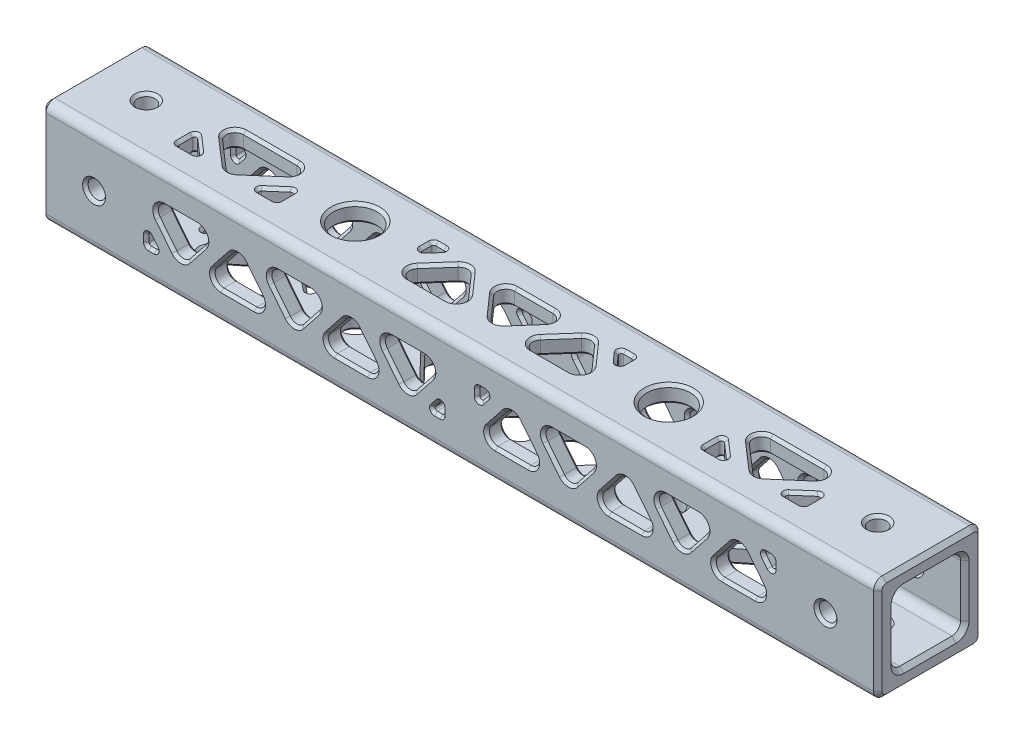
from build123d import *

# Parameters (mm, degrees)
SKETCH1_W                          = 19.05
SKETCH1_H                          = 19.05
SKETCH1_W_2                        = 12.7
SKETCH1_H_2                        = 12.7
BOSS_EXTRUDE1_DEPTH                = 76.2
F_1_8_0_125_DIAMETER_HOLE1_D       = 3.175
F_1_8_0_125_DIAMETER_HOLE2_D       = 3.175
F_3_16_0_1875_DIAMETER_HOLE1_D     = 4.7625
F_3_16_0_1875_DIAMETER_HOLE1_DEPTH = 3.175
CUT_EXTRUDE3_REACH                 = 21.05
SKETCH10_R                         = 3.96875
CUT_EXTRUDE2_REACH                 = 21.05
CUT_EXTRUDE4_REACH                 = 21.05
CUT_EXTRUDE5_DEPTH                 = 3.175
CIRPATTERN2_COUNT                  = 4
FILLET1_R                          = 1.5875
FILLET2_R                          = 0.396875
CHAMFER2_SIZE                      = 0.762
CHAMFER3_SIZE                      = 0.508


with BuildPart() as part:
    # Sketch1 → Boss-Extrude1 (new body, symmetric)
    with BuildSketch(Plane(origin=(0, 0, 0), x_dir=(0, 0, -1), z_dir=(1, 0, 0))):
        Rectangle(SKETCH1_W, SKETCH1_H)
        Rectangle(SKETCH1_W_2, SKETCH1_H_2, mode=Mode.SUBTRACT)
    extrude(amount=BOSS_EXTRUDE1_DEPTH, both=True)

    # 1/8 (0.125) Diameter Hole1 (through all)
    with Locations(Plane.XY.offset(9.525)):
        with Locations((-66.675, 0), (66.675, 0)):
            Hole(F_1_8_0_125_DIAMETER_HOLE1_D / 2)

    # 1/8 (0.125) Diameter Hole2 (through all)
    with Locations(Plane(origin=(0, 9.525, 0), x_dir=(1, 0, 0), z_dir=(0, 1, 0))):
        with Locations((-66.675, 0), (66.675, 0)):
            Hole(F_1_8_0_125_DIAMETER_HOLE2_D / 2)

    # 3/16 (0.1875) Diameter Hole1
    with Locations(Plane(origin=(0, -9.525, 0), x_dir=(-1, 0, 0), z_dir=(0, -1, 0))):
        with Locations((28.575, 0), (-28.575, 0)):
            Hole(F_3_16_0_1875_DIAMETER_HOLE1_D / 2, depth=F_3_16_0_1875_DIAMETER_HOLE1_DEPTH)

    # Sketch10 → Cut-Extrude3 (cut, up to next)
    with BuildSketch(Plane(origin=(0, 9.525, 0), x_dir=(1, 0, 0), z_dir=(0, 1, 0)), mode=Mode.PRIVATE) as cut_extrude3_sk1:
        with Locations((-28.575, 0)):
            Circle(SKETCH10_R)
    cut_extrude3_tool1 = extrude(cut_extrude3_sk1.sketch, amount=-CUT_EXTRUDE3_REACH, mode=Mode.PRIVATE) & part.part
    add(cut_extrude3_tool1.solids().sort_by_distance((-28.575, 9.525, 0))[0], mode=Mode.SUBTRACT)
    # Sketch10 → Cut-Extrude3 (cut, up to next)
    with BuildSketch(Plane(origin=(0, 9.525, 0), x_dir=(1, 0, 0), z_dir=(0, 1, 0)), mode=Mode.PRIVATE) as cut_extrude3_sk2:
        with Locations((28.575, 0)):
            Circle(SKETCH10_R)
    cut_extrude3_tool2 = extrude(cut_extrude3_sk2.sketch, amount=-CUT_EXTRUDE3_REACH, mode=Mode.PRIVATE) & part.part
    add(cut_extrude3_tool2.solids().sort_by_distance((28.575, 9.525, 0))[0], mode=Mode.SUBTRACT)

    # Sketch9 → Cut-Extrude2 (cut, up to next)
    with BuildSketch(Plane.XZ.offset(9.525), mode=Mode.PRIVATE) as cut_extrude2_sk1:
        Polygon((-19.84375, 3.96875), (-19.84375, 0.588438592), (-16.560790165, 3.96875), align=None)
    cut_extrude2_tool1 = extrude(cut_extrude2_sk1.sketch, amount=-CUT_EXTRUDE2_REACH, mode=Mode.PRIVATE) & part.part
    add(cut_extrude2_tool1.solids().sort_by_distance((-18.74943, -9.525, 2.84198))[0], mode=Mode.SUBTRACT)
    # Sketch9 → Cut-Extrude2 (cut, up to next)
    with BuildSketch(Plane.XZ.offset(9.525), mode=Mode.PRIVATE) as cut_extrude2_sk2:
        Polygon((-19.84375, -3.96875), (-12.134846722, 3.96875), (-4.425943443, -3.96875), align=None)
    cut_extrude2_tool2 = extrude(cut_extrude2_sk2.sketch, amount=-CUT_EXTRUDE2_REACH, mode=Mode.PRIVATE) & part.part
    add(cut_extrude2_tool2.solids().sort_by_distance((-12.134847, -9.525, -1.322917))[0], mode=Mode.SUBTRACT)
    # Sketch9 → Cut-Extrude2 (cut, up to next)
    with BuildSketch(Plane.XZ.offset(9.525), mode=Mode.PRIVATE) as cut_extrude2_sk3:
        Polygon((-7.708903278, 3.96875), (0, -3.96875), (7.708903278, 3.96875), align=None)
    cut_extrude2_tool3 = extrude(cut_extrude2_sk3.sketch, amount=-CUT_EXTRUDE2_REACH, mode=Mode.PRIVATE) & part.part
    add(cut_extrude2_tool3.solids().sort_by_distance((0, -9.525, 1.322917))[0], mode=Mode.SUBTRACT)
    # Sketch9 → Cut-Extrude2 (cut, up to next)
    with BuildSketch(Plane.XZ.offset(9.525), mode=Mode.PRIVATE) as cut_extrude2_sk4:
        Polygon((19.84375, -3.96875), (12.134846722, 3.96875), (4.425943443, -3.96875), align=None)
    cut_extrude2_tool4 = extrude(cut_extrude2_sk4.sketch, amount=-CUT_EXTRUDE2_REACH, mode=Mode.PRIVATE) & part.part
    add(cut_extrude2_tool4.solids().sort_by_distance((12.134847, -9.525, -1.322917))[0], mode=Mode.SUBTRACT)
    # Sketch9 → Cut-Extrude2 (cut, up to next)
    with BuildSketch(Plane.XZ.offset(9.525), mode=Mode.PRIVATE) as cut_extrude2_sk5:
        Polygon((16.560790165, 3.96875), (19.84375, 3.96875), (19.84375, 0.588438592), align=None)
    cut_extrude2_tool5 = extrude(cut_extrude2_sk5.sketch, amount=-CUT_EXTRUDE2_REACH, mode=Mode.PRIVATE) & part.part
    add(cut_extrude2_tool5.solids().sort_by_distance((18.74943, -9.525, 2.84198))[0], mode=Mode.SUBTRACT)
    # Sketch9 → Cut-Extrude2 (cut, up to next)
    with BuildSketch(Plane.XZ.offset(9.525), mode=Mode.PRIVATE) as cut_extrude2_sk6:
        Polygon((-37.30625, -3.96875), (-37.30625, -0.097233891), (-42.145645137, -3.96875), align=None)
    cut_extrude2_tool6 = extrude(cut_extrude2_sk6.sketch, amount=-CUT_EXTRUDE2_REACH, mode=Mode.PRIVATE) & part.part
    add(cut_extrude2_tool6.solids().sort_by_distance((-38.919382, -9.525, -2.678245))[0], mode=Mode.SUBTRACT)
    # Sketch9 → Cut-Extrude2 (cut, up to next)
    with BuildSketch(Plane.XZ.offset(9.525), mode=Mode.PRIVATE) as cut_extrude2_sk7:
        Polygon((-57.15, -3.96875), (-57.15, -0.097233891), (-52.310604863, -3.96875), align=None)
    cut_extrude2_tool7 = extrude(cut_extrude2_sk7.sketch, amount=-CUT_EXTRUDE2_REACH, mode=Mode.PRIVATE) & part.part
    add(cut_extrude2_tool7.solids().sort_by_distance((-55.536868, -9.525, -2.678245))[0], mode=Mode.SUBTRACT)
    # Sketch9 → Cut-Extrude2 (cut, up to next)
    with BuildSketch(Plane.XZ.offset(9.525), mode=Mode.PRIVATE) as cut_extrude2_sk8:
        Polygon((-57.15, 3.96875), (-47.228125, -3.96875), (-37.30625, 3.96875), align=None)
    cut_extrude2_tool8 = extrude(cut_extrude2_sk8.sketch, amount=-CUT_EXTRUDE2_REACH, mode=Mode.PRIVATE) & part.part
    add(cut_extrude2_tool8.solids().sort_by_distance((-47.228125, -9.525, 1.322917))[0], mode=Mode.SUBTRACT)
    # Sketch9 → Cut-Extrude2 (cut, up to next)
    with BuildSketch(Plane.XZ.offset(9.525), mode=Mode.PRIVATE) as cut_extrude2_sk9:
        Polygon((37.30625, -0.097233891), (37.30625, -3.96875), (42.145645137, -3.96875), align=None)
    cut_extrude2_tool9 = extrude(cut_extrude2_sk9.sketch, amount=-CUT_EXTRUDE2_REACH, mode=Mode.PRIVATE) & part.part
    add(cut_extrude2_tool9.solids().sort_by_distance((38.919382, -9.525, -2.678245))[0], mode=Mode.SUBTRACT)
    # Sketch9 → Cut-Extrude2 (cut, up to next)
    with BuildSketch(Plane.XZ.offset(9.525), mode=Mode.PRIVATE) as cut_extrude2_sk10:
        Polygon((52.310604863, -3.96875), (57.15, -3.96875), (57.15, -0.097233891), align=None)
    cut_extrude2_tool10 = extrude(cut_extrude2_sk10.sketch, amount=-CUT_EXTRUDE2_REACH, mode=Mode.PRIVATE) & part.part
    add(cut_extrude2_tool10.solids().sort_by_distance((55.536868, -9.525, -2.678245))[0], mode=Mode.SUBTRACT)
    # Sketch9 → Cut-Extrude2 (cut, up to next)
    with BuildSketch(Plane.XZ.offset(9.525), mode=Mode.PRIVATE) as cut_extrude2_sk11:
        Polygon((37.30625, 3.96875), (47.228125, -3.96875), (57.15, 3.96875), align=None)
    cut_extrude2_tool11 = extrude(cut_extrude2_sk11.sketch, amount=-CUT_EXTRUDE2_REACH, mode=Mode.PRIVATE) & part.part
    add(cut_extrude2_tool11.solids().sort_by_distance((47.228125, -9.525, 1.322917))[0], mode=Mode.SUBTRACT)

    # Sketch11 → Cut-Extrude4 (cut, up to next)
    with BuildSketch(Plane(origin=(0, 9.525, 0), x_dir=(1, 0, 0), z_dir=(0, 1, 0)), mode=Mode.PRIVATE) as cut_extrude4_sk1:
        Polygon((-57.15, -3.96875), (-57.15, -0.238746376), (-52.860495833, -3.96875), align=None)
    cut_extrude4_tool1 = extrude(cut_extrude4_sk1.sketch, amount=-CUT_EXTRUDE4_REACH, mode=Mode.PRIVATE) & part.part
    add(cut_extrude4_tool1.solids().sort_by_distance((-55.720165, 9.525, 2.725415))[0], mode=Mode.SUBTRACT)
    # Sketch11 → Cut-Extrude4 (cut, up to next)
    with BuildSketch(Plane(origin=(0, 9.525, 0), x_dir=(1, 0, 0), z_dir=(0, 1, 0)), mode=Mode.PRIVATE) as cut_extrude4_sk2:
        Polygon((-57.15, 3.96875), (-48.021875, -3.96875), (-38.89375, 3.96875), align=None)
    cut_extrude4_tool2 = extrude(cut_extrude4_sk2.sketch, amount=-CUT_EXTRUDE4_REACH, mode=Mode.PRIVATE) & part.part
    add(cut_extrude4_tool2.solids().sort_by_distance((-48.021875, 9.525, -1.322917))[0], mode=Mode.SUBTRACT)
    # Sketch11 → Cut-Extrude4 (cut, up to next)
    with BuildSketch(Plane(origin=(0, 9.525, 0), x_dir=(1, 0, 0), z_dir=(0, 1, 0)), mode=Mode.PRIVATE) as cut_extrude4_sk3:
        Polygon((-43.183254167, -3.96875), (-38.89375, -3.96875), (-38.89375, -0.238746376), align=None)
    cut_extrude4_tool3 = extrude(cut_extrude4_sk3.sketch, amount=-CUT_EXTRUDE4_REACH, mode=Mode.PRIVATE) & part.part
    add(cut_extrude4_tool3.solids().sort_by_distance((-40.323585, 9.525, 2.725415))[0], mode=Mode.SUBTRACT)
    # Sketch11 → Cut-Extrude4 (cut, up to next)
    with BuildSketch(Plane(origin=(0, 9.525, 0), x_dir=(1, 0, 0), z_dir=(0, 1, 0)), mode=Mode.PRIVATE) as cut_extrude4_sk4:
        Polygon((-18.25625, 3.96875), (-18.25625, 0.827576232), (-15.48206643, 3.96875), align=None)
    cut_extrude4_tool4 = extrude(cut_extrude4_sk4.sketch, amount=-CUT_EXTRUDE4_REACH, mode=Mode.PRIVATE) & part.part
    add(cut_extrude4_tool4.solids().sort_by_distance((-17.331522, 9.525, -2.921692))[0], mode=Mode.SUBTRACT)
    # Sketch11 → Cut-Extrude4 (cut, up to next)
    with BuildSketch(Plane(origin=(0, 9.525, 0), x_dir=(1, 0, 0), z_dir=(0, 1, 0)), mode=Mode.PRIVATE) as cut_extrude4_sk5:
        Polygon((15.48206643, 3.96875), (18.25625, 3.96875), (18.25625, 0.827576232), align=None)
    cut_extrude4_tool5 = extrude(cut_extrude4_sk5.sketch, amount=-CUT_EXTRUDE4_REACH, mode=Mode.PRIVATE) & part.part
    add(cut_extrude4_tool5.solids().sort_by_distance((17.331522, 9.525, -2.921692))[0], mode=Mode.SUBTRACT)
    # Sketch11 → Cut-Extrude4 (cut, up to next)
    with BuildSketch(Plane(origin=(0, 9.525, 0), x_dir=(1, 0, 0), z_dir=(0, 1, 0)), mode=Mode.PRIVATE) as cut_extrude4_sk6:
        Polygon((-18.25625, -3.96875), (-11.246105477, 3.96875), (-4.235960953, -3.96875), align=None)
    cut_extrude4_tool6 = extrude(cut_extrude4_sk6.sketch, amount=-CUT_EXTRUDE4_REACH, mode=Mode.PRIVATE) & part.part
    add(cut_extrude4_tool6.solids().sort_by_distance((-11.246105, 9.525, 1.322917))[0], mode=Mode.SUBTRACT)
    # Sketch11 → Cut-Extrude4 (cut, up to next)
    with BuildSketch(Plane(origin=(0, 9.525, 0), x_dir=(1, 0, 0), z_dir=(0, 1, 0)), mode=Mode.PRIVATE) as cut_extrude4_sk7:
        Polygon((-7.010144523, 3.96875), (0, -3.96875), (7.010144523, 3.96875), align=None)
    cut_extrude4_tool7 = extrude(cut_extrude4_sk7.sketch, amount=-CUT_EXTRUDE4_REACH, mode=Mode.PRIVATE) & part.part
    add(cut_extrude4_tool7.solids().sort_by_distance((0, 9.525, -1.322917))[0], mode=Mode.SUBTRACT)
    # Sketch11 → Cut-Extrude4 (cut, up to next)
    with BuildSketch(Plane(origin=(0, 9.525, 0), x_dir=(1, 0, 0), z_dir=(0, 1, 0)), mode=Mode.PRIVATE) as cut_extrude4_sk8:
        Polygon((18.25625, -3.96875), (11.246105477, 3.96875), (4.235960953, -3.96875), align=None)
    cut_extrude4_tool8 = extrude(cut_extrude4_sk8.sketch, amount=-CUT_EXTRUDE4_REACH, mode=Mode.PRIVATE) & part.part
    add(cut_extrude4_tool8.solids().sort_by_distance((11.246105, 9.525, 1.322917))[0], mode=Mode.SUBTRACT)
    # Sketch11 → Cut-Extrude4 (cut, up to next)
    with BuildSketch(Plane(origin=(0, 9.525, 0), x_dir=(1, 0, 0), z_dir=(0, 1, 0)), mode=Mode.PRIVATE) as cut_extrude4_sk9:
        Polygon((38.89375, -0.238746376), (38.89375, -3.96875), (43.183254167, -3.96875), align=None)
    cut_extrude4_tool9 = extrude(cut_extrude4_sk9.sketch, amount=-CUT_EXTRUDE4_REACH, mode=Mode.PRIVATE) & part.part
    add(cut_extrude4_tool9.solids().sort_by_distance((40.323585, 9.525, 2.725415))[0], mode=Mode.SUBTRACT)
    # Sketch11 → Cut-Extrude4 (cut, up to next)
    with BuildSketch(Plane(origin=(0, 9.525, 0), x_dir=(1, 0, 0), z_dir=(0, 1, 0)), mode=Mode.PRIVATE) as cut_extrude4_sk10:
        Polygon((52.860495833, -3.96875), (57.15, -3.96875), (57.15, -0.238746376), align=None)
    cut_extrude4_tool10 = extrude(cut_extrude4_sk10.sketch, amount=-CUT_EXTRUDE4_REACH, mode=Mode.PRIVATE) & part.part
    add(cut_extrude4_tool10.solids().sort_by_distance((55.720165, 9.525, 2.725415))[0], mode=Mode.SUBTRACT)
    # Sketch11 → Cut-Extrude4 (cut, up to next)
    with BuildSketch(Plane(origin=(0, 9.525, 0), x_dir=(1, 0, 0), z_dir=(0, 1, 0)), mode=Mode.PRIVATE) as cut_extrude4_sk11:
        Polygon((38.89375, 3.96875), (48.021875, -3.96875), (57.15, 3.96875), align=None)
    cut_extrude4_tool11 = extrude(cut_extrude4_sk11.sketch, amount=-CUT_EXTRUDE4_REACH, mode=Mode.PRIVATE) & part.part
    add(cut_extrude4_tool11.solids().sort_by_distance((48.021875, 9.525, -1.322917))[0], mode=Mode.SUBTRACT)

    # Sketch13 → Cut-Extrude5 (cut)
    with BuildSketch(Plane.XY.offset(9.525)):
        Polygon((-57.15, -1.141145373), (-57.15, -3.96875), (-54.907718384, -3.96875), align=None)
        Polygon((-3.175, -3.96875), (-3.175, -1.141145373), (-5.417281616, -3.96875), align=None)
        Polygon((-30.1625, -3.96875), (-36.456912646, 3.96875), (-23.868087354, 3.96875), align=None)
        Polygon((-57.15, 3.96875), (-50.855587354, -3.96875), (-44.561174708, 3.96875), align=None)
        Polygon((-3.175, 3.96875), (-9.469412646, -3.96875), (-15.763825292, 3.96875), align=None)
        Polygon((-46.803456323, -3.96875), (-40.509043677, 3.96875), (-34.214631031, -3.96875), align=None)
        Polygon((-26.110368969, -3.96875), (-19.815956323, 3.96875), (-13.521543677, -3.96875), align=None)
        Polygon((3.175, 3.96875), (3.175, 1.141145373), (5.417281616, 3.96875), align=None)
        Polygon((57.15, 3.96875), (57.15, 1.141145373), (54.907718384, 3.96875), align=None)
        Polygon((23.868087354, -3.96875), (30.1625, 3.96875), (36.456912646, -3.96875), align=None)
        Polygon((3.175, -3.96875), (9.469412646, 3.96875), (15.763825292, -3.96875), align=None)
        Polygon((13.521543677, 3.96875), (19.815956323, -3.96875), (26.110368969, 3.96875), align=None)
        Polygon((57.15, -3.96875), (50.855587354, 3.96875), (44.561174708, -3.96875), align=None)
        Polygon((34.214631031, 3.96875), (40.509043677, -3.96875), (46.803456323, 3.96875), align=None)
    cut_extrude5 = extrude(amount=-CUT_EXTRUDE5_DEPTH, mode=Mode.SUBTRACT)

    # CirPattern2: Cut-Extrude5 ×4 about axis, 2 skipped
    cirpattern2_axis = Axis((-82.07375, 0, 0), (1, 0, 0))
    add([cut_extrude5.rotate(cirpattern2_axis, i * 360 / CIRPATTERN2_COUNT) for i in range(1, CIRPATTERN2_COUNT) if i not in (1, 3)], mode=Mode.SUBTRACT)

    # Fillet1
    fillet1_edges = [part.edges().sort_by_distance(p)[0] for p in [
        (47.228125, -7.9375, -3.96875),
        (57.15, -7.9375, 3.96875),
        (37.30625, -7.9375, 3.96875),
        (12.134846722, -7.9375, 3.96875),
        (4.425943443, -7.9375, -3.96875),
        (19.84375, -7.9375, -3.96875),
        (-12.134846722, -7.9375, 3.96875),
        (-19.84375, -7.9375, -3.96875),
        (-4.425943443, -7.9375, -3.96875),
        (0, -6.35, -6.35),
        (0, 6.35, -6.35),
        (0, -7.9375, -3.96875),
        (7.708903278, -7.9375, 3.96875),
        (-7.708903278, -7.9375, 3.96875),
        (0, 6.35, 6.35),
        (-47.228125, -7.9375, -3.96875),
        (-37.30625, -7.9375, 3.96875),
        (-57.15, -7.9375, 3.96875),
        (0, -6.35, 6.35),
        (-4.235960953, 7.9375, 3.96875),
        (-18.25625, 7.9375, 3.96875),
        (-11.246105477, 7.9375, -3.96875),
        (18.25625, 7.9375, 3.96875),
        (4.235960953, 7.9375, 3.96875),
        (11.246105477, 7.9375, -3.96875),
        (38.89375, 7.9375, -3.96875),
        (57.15, 7.9375, -3.96875),
        (48.021875, 7.9375, 3.96875),
        (-7.010144523, 7.9375, -3.96875),
        (0, 7.9375, 3.96875),
        (7.010144523, 7.9375, -3.96875),
        (-57.15, 7.9375, -3.96875),
        (-38.89375, 7.9375, -3.96875),
        (-48.021875, 7.9375, 3.96875),
        (50.855587354, 3.96875, 7.9375),
        (44.561174708, -3.96875, 7.9375),
        (57.15, -3.96875, 7.9375),
        (-36.456912646, 3.96875, 7.9375),
        (-30.1625, -3.96875, 7.9375),
        (-23.868087354, 3.96875, 7.9375),
        (-9.469412646, -3.96875, 7.9375),
        (-3.175, 3.96875, 7.9375),
        (-15.763825292, 3.96875, 7.9375),
        (9.469412646, 3.96875, 7.9375),
        (3.175, -3.96875, 7.9375),
        (15.763825292, -3.96875, 7.9375),
        (40.509043677, -3.96875, 7.9375),
        (46.803456323, 3.96875, 7.9375),
        (34.214631031, 3.96875, 7.9375),
        (30.1625, 3.96875, 7.9375),
        (23.868087354, -3.96875, 7.9375),
        (36.456912646, -3.96875, 7.9375),
        (19.815956323, -3.96875, 7.9375),
        (26.110368969, 3.96875, 7.9375),
        (13.521543677, 3.96875, 7.9375),
        (-19.815956323, 3.96875, 7.9375),
        (-26.110368969, -3.96875, 7.9375),
        (-13.521543677, -3.96875, 7.9375),
        (-40.509043677, 3.96875, 7.9375),
        (-46.803456323, -3.96875, 7.9375),
        (-34.214631031, -3.96875, 7.9375),
        (-50.855587354, -3.96875, 7.9375),
        (-44.561174708, 3.96875, 7.9375),
        (-57.15, 3.96875, 7.9375),
        (57.15, 3.96875, -7.9375),
        (44.561174708, 3.96875, -7.9375),
        (50.855587354, -3.96875, -7.9375),
        (-36.456912646, -3.96875, -7.9375),
        (-30.1625, 3.96875, -7.9375),
        (-23.868087354, -3.96875, -7.9375),
        (-15.763825292, -3.96875, -7.9375),
        (-3.175, -3.96875, -7.9375),
        (-9.469412646, 3.96875, -7.9375),
        (15.763825292, 3.96875, -7.9375),
        (3.175, 3.96875, -7.9375),
        (9.469412646, -3.96875, -7.9375),
        (34.214631031, -3.96875, -7.9375),
        (46.803456323, -3.96875, -7.9375),
        (40.509043677, 3.96875, -7.9375),
        (36.456912646, 3.96875, -7.9375),
        (23.868087354, 3.96875, -7.9375),
        (30.1625, -3.96875, -7.9375),
        (13.521543677, -3.96875, -7.9375),
        (26.110368969, -3.96875, -7.9375),
        (19.815956323, 3.96875, -7.9375),
        (-13.521543677, 3.96875, -7.9375),
        (-26.110368969, 3.96875, -7.9375),
        (-19.815956323, -3.96875, -7.9375),
        (-34.214631031, 3.96875, -7.9375),
        (-46.803456323, 3.96875, -7.9375),
        (-40.509043677, -3.96875, -7.9375),
        (-57.15, -3.96875, -7.9375),
        (-44.561174708, -3.96875, -7.9375),
        (-50.855587354, 3.96875, -7.9375),
        (0, -9.525, -9.525),
        (0, -9.525, 9.525),
        (0, 9.525, 9.525),
        (0, 9.525, -9.525),
    ]]
    fillet(fillet1_edges, radius=FILLET1_R)

    # Fillet2
    fillet2_edges = [part.edges().sort_by_distance(p)[0] for p in [
        (37.30625, -7.9375, -0.097233891),
        (37.30625, -7.9375, -3.96875),
        (42.145645137, -7.9375, -3.96875),
        (16.560790165, -7.9375, 3.96875),
        (19.84375, -7.9375, 0.588438592),
        (19.84375, -7.9375, 3.96875),
        (-19.84375, -7.9375, 0.588438592),
        (-16.560790165, -7.9375, 3.96875),
        (-19.84375, -7.9375, 3.96875),
        (-37.30625, -7.9375, -0.097233891),
        (-42.145645137, -7.9375, -3.96875),
        (-37.30625, -7.9375, -3.96875),
        (-57.15, -7.9375, -0.097233891),
        (-57.15, -7.9375, -3.96875),
        (-52.310604863, -7.9375, -3.96875),
        (52.310604863, -7.9375, -3.96875),
        (57.15, -7.9375, -3.96875),
        (57.15, -7.9375, -0.097233891),
        (-38.89375, 7.9375, 3.96875),
        (-38.89375, 7.9375, 0.238746376),
        (-43.183254167, 7.9375, 3.96875),
        (43.183254167, 7.9375, 3.96875),
        (38.89375, 7.9375, 3.96875),
        (38.89375, 7.9375, 0.238746376),
        (57.15, 7.9375, 0.238746376),
        (57.15, 7.9375, 3.96875),
        (52.860495833, 7.9375, 3.96875),
        (15.48206643, 7.9375, -3.96875),
        (18.25625, 7.9375, -0.827576232),
        (18.25625, 7.9375, -3.96875),
        (-18.25625, 7.9375, -3.96875),
        (-15.48206643, 7.9375, -3.96875),
        (-18.25625, 7.9375, -0.827576232),
        (-52.860495833, 7.9375, 3.96875),
        (-57.15, 7.9375, 3.96875),
        (-57.15, 7.9375, 0.238746376),
        (3.175, 1.141145373, 7.9375),
        (5.417281616, 3.96875, 7.9375),
        (3.175, 3.96875, 7.9375),
        (57.15, 1.141145373, 7.9375),
        (57.15, 3.96875, 7.9375),
        (54.907718384, 3.96875, 7.9375),
        (-57.15, -1.141145373, 7.9375),
        (-57.15, -3.96875, 7.9375),
        (-54.907718384, -3.96875, 7.9375),
        (-3.175, -1.141145373, 7.9375),
        (-5.417281616, -3.96875, 7.9375),
        (-3.175, -3.96875, 7.9375),
        (3.175, -3.96875, -7.9375),
        (3.175, -1.141145373, -7.9375),
        (5.417281616, -3.96875, -7.9375),
        (54.907718384, -3.96875, -7.9375),
        (57.15, -3.96875, -7.9375),
        (57.15, -1.141145373, -7.9375),
        (-54.907718384, 3.96875, -7.9375),
        (-57.15, 3.96875, -7.9375),
        (-57.15, 1.141145373, -7.9375),
        (-3.175, 3.96875, -7.9375),
        (-3.175, 1.141145373, -7.9375),
        (-5.417281616, 3.96875, -7.9375),
    ]]
    fillet(fillet2_edges, radius=FILLET2_R)

    # Chamfer2
    chamfer2_edges = [part.edges().sort_by_distance(p)[0] for p in [
        (-76.2, 0, -6.35),
        (76.2, 0, -6.35),
        (-76.2, 6.35, 0),
        (76.2, 6.35, 0),
        (-76.2, -6.35, 0),
        (76.2, -6.35, 0),
        (-76.2, 0, 6.35),
        (76.2, 0, 6.35),
        (-76.2, 0, -9.525),
        (76.2, 0, -9.525),
        (-76.2, -9.525, 0),
        (-76.2, 0, 9.525),
        (-76.2, 9.525, 0),
        (-76.2, 9.060032015, 9.060032015),
        (-76.2, 9.060032015, -9.060032015),
        (-76.2, -9.060032015, 9.060032015),
        (-76.2, -9.060032015, -9.060032015),
        (76.2, -9.525, 0),
        (76.2, 9.525, 0),
        (76.2, 0, 9.525),
        (76.2, 9.060032015, 9.060032015),
        (76.2, 9.060032015, -9.060032015),
        (76.2, -9.060032015, 9.060032015),
        (76.2, -9.060032015, -9.060032015),
        (-76.2, 5.885032015, -5.885032015),
        (76.2, 5.885032015, -5.885032015),
        (-76.2, -5.885032015, -5.885032015),
        (76.2, -5.885032015, -5.885032015),
        (-76.2, -5.885032015, 5.885032015),
        (76.2, -5.885032015, 5.885032015),
        (-76.2, 5.885032015, 5.885032015),
        (76.2, 5.885032015, 5.885032015),
    ]]
    chamfer(chamfer2_edges, length=CHAMFER2_SIZE)

    # Chamfer3
    chamfer3_edges = [part.edges().sort_by_distance(p)[0] for p in [
        (56.241040198, -3.96875, -9.525),
        (56.241040198, -3.96875, -6.35),
        (57.15, -2.926116079, -9.525),
        (57.15, -2.926116079, -6.35),
        (55.930073421, -2.679520399, -9.525),
        (55.930073421, -2.679520399, -6.35),
        (4.083959802, -3.96875, -9.525),
        (4.083959802, -3.96875, -6.35),
        (4.394926579, -2.679520399, -9.525),
        (4.394926579, -2.679520399, -6.35),
        (3.175, -2.926116079, -9.525),
        (3.175, -2.926116079, -6.35),
        (-4.083959802, 3.96875, -9.525),
        (-4.083959802, 3.96875, -6.35),
        (-4.394926579, 2.679520399, -9.525),
        (-4.394926579, 2.679520399, -6.35),
        (-3.175, 2.926116079, -9.525),
        (-3.175, 2.926116079, -6.35),
        (-56.241040198, 3.96875, -9.525),
        (-56.241040198, 3.96875, -6.35),
        (-57.15, 2.926116079, -9.525),
        (-57.15, 2.926116079, -6.35),
        (-55.930073421, 2.679520399, -9.525),
        (-55.930073421, 2.679520399, -6.35),
        (17.110721888, 9.525, -3.96875),
        (17.110721888, 6.35, -3.96875),
        (18.25625, 9.525, -2.724184334),
        (18.25625, 6.35, -2.724184334),
        (16.813250278, 9.525, -2.461466982),
        (16.813250278, 6.35, -2.461466982),
        (-17.110721888, 9.525, -3.96875),
        (-17.110721888, 6.35, -3.96875),
        (-16.813250278, 9.525, -2.461466982),
        (-16.813250278, 6.35, -2.461466982),
        (-18.25625, 9.525, -2.724184334),
        (-18.25625, 6.35, -2.724184334),
        (3.175, 2.926116079, 9.525),
        (3.175, 2.926116079, 6.35),
        (4.083959802, 3.96875, 9.525),
        (4.083959802, 3.96875, 6.35),
        (4.394926579, 2.679520399, 9.525),
        (4.394926579, 2.679520399, 6.35),
        (55.930073421, 2.679520399, 9.525),
        (55.930073421, 2.679520399, 6.35),
        (56.241040198, 3.96875, 9.525),
        (56.241040198, 3.96875, 6.35),
        (57.15, 2.926116079, 9.525),
        (57.15, 2.926116079, 6.35),
        (-3.175, -2.926116079, 9.525),
        (-3.175, -2.926116079, 6.35),
        (-4.083959802, -3.96875, 9.525),
        (-4.083959802, -3.96875, 6.35),
        (-4.394926579, -2.679520399, 9.525),
        (-4.394926579, -2.679520399, 6.35),
        (-55.930073421, -2.679520399, 9.525),
        (-55.930073421, -2.679520399, 6.35),
        (-56.241040198, -3.96875, 9.525),
        (-56.241040198, -3.96875, 6.35),
        (-57.15, -2.926116079, 9.525),
        (-57.15, -2.926116079, 6.35),
        (55.337427343, 9.525, 3.96875),
        (55.337427343, 6.35, 3.96875),
        (55.077006416, 9.525, 2.041349493),
        (55.077006416, 6.35, 2.041349493),
        (57.15, 9.525, 2.340833559),
        (57.15, 6.35, 2.340833559),
        (38.89375, 9.525, 2.340833559),
        (38.89375, 6.35, 2.340833559),
        (40.966743584, 9.525, 2.041349493),
        (40.966743584, 6.35, 2.041349493),
        (40.706322657, 9.525, 3.96875),
        (40.706322657, 6.35, 3.96875),
        (-40.706322657, 9.525, 3.96875),
        (-40.706322657, 6.35, 3.96875),
        (-40.966743584, 9.525, 2.041349493),
        (-40.966743584, 6.35, 2.041349493),
        (-38.89375, 9.525, 2.340833559),
        (-38.89375, 6.35, 2.340833559),
        (-57.15, 9.525, 2.340833559),
        (-57.15, 6.35, 2.340833559),
        (-55.077006416, 9.525, 2.041349493),
        (-55.077006416, 6.35, 2.041349493),
        (-55.337427343, 9.525, 3.96875),
        (-55.337427343, 6.35, 3.96875),
        (54.849640951, -9.525, -1.93752113),
        (54.849640951, -6.35, -1.93752113),
        (57.15, -9.525, -2.247428439),
        (57.15, -6.35, -2.247428439),
        (55.097566798, -9.525, -3.96875),
        (55.097566798, -6.35, -3.96875),
        (39.606609049, -9.525, -1.93752113),
        (39.606609049, -6.35, -1.93752113),
        (39.358683202, -9.525, -3.96875),
        (39.358683202, -6.35, -3.96875),
        (37.30625, -9.525, -2.247428439),
        (37.30625, -6.35, -2.247428439),
        (18.473176629, -9.525, 3.96875),
        (18.473176629, -6.35, 3.96875),
        (19.84375, -9.525, 2.569302969),
        (19.84375, -6.35, 2.569302969),
        (18.188473912, -9.525, 2.292799572),
        (18.188473912, -6.35, 2.292799572),
        (-19.84375, -9.525, 2.569302969),
        (-19.84375, -6.35, 2.569302969),
        (-18.473176629, -9.525, 3.96875),
        (-18.473176629, -6.35, 3.96875),
        (-18.188473912, -9.525, 2.292799572),
        (-18.188473912, -6.35, 2.292799572),
        (-39.358683202, -9.525, -3.96875),
        (-39.358683202, -6.35, -3.96875),
        (-39.606609049, -9.525, -1.93752113),
        (-39.606609049, -6.35, -1.93752113),
        (-37.30625, -9.525, -2.247428439),
        (-37.30625, -6.35, -2.247428439),
        (-54.849640951, -9.525, -1.93752113),
        (-54.849640951, -6.35, -1.93752113),
        (-55.097566798, -9.525, -3.96875),
        (-55.097566798, -6.35, -3.96875),
        (-57.15, -9.525, -2.247428439),
        (-57.15, -6.35, -2.247428439),
        (57.033758004, -3.852508004, -9.525),
        (57.033758004, -3.852508004, -6.35),
        (55.371619821, -3.744562731, -9.525),
        (55.371619821, -3.744562731, -6.35),
        (56.883690742, -1.905574084, -9.525),
        (56.883690742, -1.905574084, -6.35),
        (4.953380179, -3.744562731, -9.525),
        (4.953380179, -3.744562731, -6.35),
        (3.291241996, -3.852508004, -9.525),
        (3.291241996, -3.852508004, -6.35),
        (3.441309258, -1.905574084, -9.525),
        (3.441309258, -1.905574084, -6.35),
        (-4.953380179, 3.744562731, -9.525),
        (-4.953380179, 3.744562731, -6.35),
        (-3.441309258, 1.905574084, -9.525),
        (-3.441309258, 1.905574084, -6.35),
        (-3.291241996, 3.852508004, -9.525),
        (-3.291241996, 3.852508004, -6.35),
        (-57.033758004, 3.852508004, -9.525),
        (-57.033758004, 3.852508004, -6.35),
        (-56.883690742, 1.905574084, -9.525),
        (-56.883690742, 1.905574084, -6.35),
        (-55.371619821, 3.744562731, -9.525),
        (-55.371619821, 3.744562731, -6.35),
        (18.140008004, 9.525, -3.852508004),
        (18.140008004, 6.35, -3.852508004),
        (17.999822001, 9.525, -1.50530045),
        (17.999822001, 6.35, -1.50530045),
        (16.000284506, 9.525, -3.735037215),
        (16.000284506, 6.35, -3.735037215),
        (-16.000284506, 9.525, -3.735037215),
        (-16.000284506, 6.35, -3.735037215),
        (-17.999822001, 9.525, -1.50530045),
        (-17.999822001, 6.35, -1.50530045),
        (-18.140008004, 9.525, -3.852508004),
        (-18.140008004, 6.35, -3.852508004),
        (3.291241996, 3.852508004, 9.525),
        (3.291241996, 3.852508004, 6.35),
        (3.441309258, 1.905574084, 9.525),
        (3.441309258, 1.905574084, 6.35),
        (4.953380179, 3.744562731, 9.525),
        (4.953380179, 3.744562731, 6.35),
        (55.371619821, 3.744562731, 9.525),
        (55.371619821, 3.744562731, 6.35),
        (56.883690742, 1.905574084, 9.525),
        (56.883690742, 1.905574084, 6.35),
        (57.033758004, 3.852508004, 9.525),
        (57.033758004, 3.852508004, 6.35),
        (-3.291241996, -3.852508004, 9.525),
        (-3.291241996, -3.852508004, 6.35),
        (-3.441309258, -1.905574084, 9.525),
        (-3.441309258, -1.905574084, 6.35),
        (-4.953380179, -3.744562731, 9.525),
        (-4.953380179, -3.744562731, 6.35),
        (-55.371619821, -3.744562731, 9.525),
        (-55.371619821, -3.744562731, 6.35),
        (-56.883690742, -1.905574084, 9.525),
        (-56.883690742, -1.905574084, 6.35),
        (-57.033758004, -3.852508004, 9.525),
        (-57.033758004, -3.852508004, 6.35),
        (53.549998934, 9.525, 3.710893032),
        (53.549998934, 6.35, 3.710893032),
        (56.917677742, 9.525, 0.74863819),
        (56.917677742, 6.35, 0.74863819),
        (57.033758004, 9.525, 3.852508004),
        (57.033758004, 6.35, 3.852508004),
        (39.126072258, 9.525, 0.74863819),
        (39.126072258, 6.35, 0.74863819),
        (42.493751066, 9.525, 3.710893032),
        (42.493751066, 6.35, 3.710893032),
        (39.009991996, 9.525, 3.852508004),
        (39.009991996, 6.35, 3.852508004),
        (-42.493751066, 9.525, 3.710893032),
        (-42.493751066, 6.35, 3.710893032),
        (-39.126072258, 9.525, 0.74863819),
        (-39.126072258, 6.35, 0.74863819),
        (-39.009991996, 9.525, 3.852508004),
        (-39.009991996, 6.35, 3.852508004),
        (-56.917677742, 9.525, 0.74863819),
        (-56.917677742, 6.35, 0.74863819),
        (-53.549998934, 9.525, 3.710893032),
        (-53.549998934, 6.35, 3.710893032),
        (-57.033758004, 9.525, 3.852508004),
        (-57.033758004, 6.35, 3.852508004),
        (56.925046777, -9.525, -0.565277155),
        (56.925046777, -6.35, -0.565277155),
        (53.067506107, -9.525, -3.70324338),
        (53.067506107, -6.35, -3.70324338),
        (57.033758004, -9.525, -3.852508004),
        (57.033758004, -6.35, -3.852508004),
        (41.388743893, -9.525, -3.70324338),
        (41.388743893, -6.35, -3.70324338),
        (37.531203223, -9.525, -0.565277155),
        (37.531203223, -6.35, -0.565277155),
        (37.422491996, -9.525, -3.852508004),
        (37.422491996, -6.35, -3.852508004),
        (19.727508004, -9.525, 3.852508004),
        (19.727508004, -6.35, 3.852508004),
        (17.133932741, -9.525, 3.726426739),
        (17.133932741, -6.35, 3.726426739),
        (19.596070132, -9.525, 1.198966641),
        (19.596070132, -6.35, 1.198966641),
        (-19.727508004, -9.525, 3.852508004),
        (-19.727508004, -6.35, 3.852508004),
        (-17.133932741, -9.525, 3.726426739),
        (-17.133932741, -6.35, 3.726426739),
        (-19.596070132, -9.525, 1.198966641),
        (-19.596070132, -6.35, 1.198966641),
        (-41.388743893, -9.525, -3.70324338),
        (-41.388743893, -6.35, -3.70324338),
        (-37.531203223, -9.525, -0.565277155),
        (-37.531203223, -6.35, -0.565277155),
        (-37.422491996, -9.525, -3.852508004),
        (-37.422491996, -6.35, -3.852508004),
        (-53.067506107, -9.525, -3.70324338),
        (-53.067506107, -6.35, -3.70324338),
        (-56.925046777, -9.525, -0.565277155),
        (-56.925046777, -6.35, -0.565277155),
        (-57.033758004, -9.525, -3.852508004),
        (-57.033758004, -6.35, -3.852508004),
        (68.2625, 0, 6.35),
        (68.2625, 0, -6.35),
        (68.2625, 0, -9.525),
        (68.2625, 0, 9.525),
        (-65.0875, 0, 6.35),
        (-65.0875, 0, -6.35),
        (-65.0875, 0, -9.525),
        (-65.0875, 0, 9.525),
        (68.2625, -6.35, 0),
        (68.2625, 6.35, 0),
        (68.2625, 9.525, 0),
        (68.2625, -9.525, 0),
        (-65.0875, -6.35, 0),
        (-65.0875, 6.35, 0),
        (-65.0875, 9.525, 0),
        (-65.0875, -9.525, 0),
        (48.106987947, -0.502658877, -9.525),
        (48.106987947, -0.502658877, -6.35),
        (53.604186761, -0.502658877, -9.525),
        (53.604186761, -0.502658877, -6.35),
        (50.855587354, 3.96875, -9.525),
        (50.855587354, 3.96875, -6.35),
        (40.509043677, -3.96875, -9.525),
        (40.509043677, -3.96875, -6.35),
        (43.257643084, 0.502658877, -9.525),
        (43.257643084, 0.502658877, -6.35),
        (37.76044427, 0.502658877, -9.525),
        (37.76044427, 0.502658877, -6.35),
        (27.413900593, -0.502658877, -9.525),
        (27.413900593, -0.502658877, -6.35),
        (32.911099407, -0.502658877, -9.525),
        (32.911099407, -0.502658877, -6.35),
        (30.1625, 3.96875, -9.525),
        (30.1625, 3.96875, -6.35),
        (19.815956323, -3.96875, -9.525),
        (19.815956323, -3.96875, -6.35),
        (22.56455573, 0.502658877, -9.525),
        (22.56455573, 0.502658877, -6.35),
        (17.067356916, 0.502658877, -9.525),
        (17.067356916, 0.502658877, -6.35),
        (6.720813239, -0.502658877, -9.525),
        (6.720813239, -0.502658877, -6.35),
        (12.218012053, -0.502658877, -9.525),
        (12.218012053, -0.502658877, -6.35),
        (9.469412646, 3.96875, -9.525),
        (9.469412646, 3.96875, -6.35),
        (-9.469412646, -3.96875, -9.525),
        (-9.469412646, -3.96875, -6.35),
        (-6.720813239, 0.502658877, -9.525),
        (-6.720813239, 0.502658877, -6.35),
        (-12.218012053, 0.502658877, -9.525),
        (-12.218012053, 0.502658877, -6.35),
        (26.19375, -9.525, 0),
        (26.19375, -6.35, 0),
        (-22.56455573, -0.502658877, -9.525),
        (-22.56455573, -0.502658877, -6.35),
        (-17.067356916, -0.502658877, -9.525),
        (-17.067356916, -0.502658877, -6.35),
        (-19.815956323, 3.96875, -9.525),
        (-19.815956323, 3.96875, -6.35),
        (-30.1625, -3.96875, -9.525),
        (-30.1625, -3.96875, -6.35),
        (-27.413900593, 0.502658877, -9.525),
        (-27.413900593, 0.502658877, -6.35),
        (-32.911099407, 0.502658877, -9.525),
        (-32.911099407, 0.502658877, -6.35),
        (-43.257643084, -0.502658877, -9.525),
        (-43.257643084, -0.502658877, -6.35),
        (-37.76044427, -0.502658877, -9.525),
        (-37.76044427, -0.502658877, -6.35),
        (-40.509043677, 3.96875, -9.525),
        (-40.509043677, 3.96875, -6.35),
        (-50.855587354, -3.96875, -9.525),
        (-50.855587354, -3.96875, -6.35),
        (-48.106987947, 0.502658877, -9.525),
        (-48.106987947, 0.502658877, -6.35),
        (-53.604186761, 0.502658877, -9.525),
        (-53.604186761, 0.502658877, -6.35),
        (47.228125, -9.525, 3.96875),
        (47.228125, -6.35, 3.96875),
        (50.917958422, -9.525, -1.016883262),
        (50.917958422, -6.35, -1.016883262),
        (43.538291578, -9.525, -1.016883262),
        (43.538291578, -6.35, -1.016883262),
        (15.250733041, -9.525, 0.760466439),
        (15.250733041, -6.35, 0.760466439),
        (12.134846722, -9.525, -3.96875),
        (12.134846722, -6.35, -3.96875),
        (9.018960402, -9.525, 0.760466439),
        (9.018960402, -6.35, 0.760466439),
        (-3.11588632, -9.525, -0.760466439),
        (-3.11588632, -6.35, -0.760466439),
        (0, -9.525, 3.96875),
        (0, -6.35, 3.96875),
        (3.11588632, -9.525, -0.760466439),
        (3.11588632, -6.35, -0.760466439),
        (-9.018960402, -9.525, 0.760466439),
        (-9.018960402, -6.35, 0.760466439),
        (-12.134846722, -9.525, -3.96875),
        (-12.134846722, -6.35, -3.96875),
        (-30.95625, -9.525, 0),
        (-15.250733041, -9.525, 0.760466439),
        (-15.250733041, -6.35, 0.760466439),
        (-30.95625, -6.35, 0),
        (-50.917958422, -9.525, -1.016883262),
        (-50.917958422, -6.35, -1.016883262),
        (-47.228125, -9.525, 3.96875),
        (-47.228125, -6.35, 3.96875),
        (-43.538291578, -9.525, -1.016883262),
        (-43.538291578, -6.35, -1.016883262),
        (53.604186761, 0.502658877, 9.525),
        (53.604186761, 0.502658877, 6.35),
        (50.855587354, -3.96875, 9.525),
        (50.855587354, -3.96875, 6.35),
        (48.106987947, 0.502658877, 9.525),
        (48.106987947, 0.502658877, 6.35),
        (37.76044427, -0.502658877, 9.525),
        (37.76044427, -0.502658877, 6.35),
        (40.509043677, 3.96875, 9.525),
        (40.509043677, 3.96875, 6.35),
        (43.257643084, -0.502658877, 9.525),
        (43.257643084, -0.502658877, 6.35),
        (32.911099407, 0.502658877, 9.525),
        (32.911099407, 0.502658877, 6.35),
        (30.1625, -3.96875, 9.525),
        (30.1625, -3.96875, 6.35),
        (27.413900593, 0.502658877, 9.525),
        (27.413900593, 0.502658877, 6.35),
        (17.067356916, -0.502658877, 9.525),
        (17.067356916, -0.502658877, 6.35),
        (19.815956323, 3.96875, 9.525),
        (19.815956323, 3.96875, 6.35),
        (22.56455573, -0.502658877, 9.525),
        (22.56455573, -0.502658877, 6.35),
        (12.218012053, 0.502658877, 9.525),
        (12.218012053, 0.502658877, 6.35),
        (9.469412646, -3.96875, 9.525),
        (9.469412646, -3.96875, 6.35),
        (6.720813239, 0.502658877, 9.525),
        (6.720813239, 0.502658877, 6.35),
        (-12.218012053, -0.502658877, 9.525),
        (-12.218012053, -0.502658877, 6.35),
        (-9.469412646, 3.96875, 9.525),
        (-9.469412646, 3.96875, 6.35),
        (-6.720813239, -0.502658877, 9.525),
        (-6.720813239, -0.502658877, 6.35),
        (-17.067356916, 0.502658877, 9.525),
        (-17.067356916, 0.502658877, 6.35),
        (-19.815956323, -3.96875, 9.525),
        (-19.815956323, -3.96875, 6.35),
        (-22.56455573, 0.502658877, 9.525),
        (-22.56455573, 0.502658877, 6.35),
        (-30.1625, 3.96875, 9.525),
        (-30.1625, 3.96875, 6.35),
        (-27.413900593, -0.502658877, 9.525),
        (-27.413900593, -0.502658877, 6.35),
        (-32.911099407, -0.502658877, 9.525),
        (-32.911099407, -0.502658877, 6.35),
        (-37.76044427, 0.502658877, 9.525),
        (-37.76044427, 0.502658877, 6.35),
        (-40.509043677, -3.96875, 9.525),
        (-40.509043677, -3.96875, 6.35),
        (-43.257643084, 0.502658877, 9.525),
        (-43.257643084, 0.502658877, 6.35),
        (-32.54375, 6.35, 0),
        (-53.604186761, -0.502658877, 9.525),
        (-53.604186761, -0.502658877, 6.35),
        (-32.54375, 9.525, 0),
        (-50.855587354, 3.96875, 9.525),
        (-50.855587354, 3.96875, 6.35),
        (-48.106987947, -0.502658877, 9.525),
        (-48.106987947, -0.502658877, 6.35),
        (48.021875, 9.525, -3.96875),
        (48.021875, 6.35, -3.96875),
        (51.505153502, 9.525, 0.939812172),
        (51.505153502, 6.35, 0.939812172),
        (44.538596498, 9.525, 0.939812172),
        (44.538596498, 6.35, 0.939812172),
        (8.311151465, 9.525, -0.645537848),
        (8.311151465, 6.35, -0.645537848),
        (14.181059488, 9.525, -0.645537848),
        (24.60625, 6.35, 0),
        (14.181059488, 6.35, -0.645537848),
        (24.60625, 9.525, 0),
        (11.246105477, 9.525, 3.96875),
        (11.246105477, 6.35, 3.96875),
        (0, 9.525, -3.96875),
        (0, 6.35, -3.96875),
        (2.934954011, 9.525, 0.645537848),
        (2.934954011, 6.35, 0.645537848),
        (-2.934954011, 9.525, 0.645537848),
        (-2.934954011, 6.35, 0.645537848),
        (-11.246105477, 9.525, 3.96875),
        (-11.246105477, 6.35, 3.96875),
        (-14.181059488, 9.525, -0.645537848),
        (-14.181059488, 6.35, -0.645537848),
        (-8.311151465, 9.525, -0.645537848),
        (-8.311151465, 6.35, -0.645537848),
        (-48.021875, 9.525, -3.96875),
        (-48.021875, 6.35, -3.96875),
        (-44.538596498, 9.525, 0.939812172),
        (-44.538596498, 6.35, 0.939812172),
        (-51.505153502, 9.525, 0.939812172),
        (-51.505153502, 6.35, 0.939812172),
        (50.855587354, -3.001302314, -9.525),
        (50.855587354, -3.001302314, -6.35),
        (55.294394255, 3.072000925, -9.525),
        (55.294394255, 3.072000925, -6.35),
        (46.416780453, 3.072000925, -9.525),
        (46.416780453, 3.072000925, -6.35),
        (44.947850578, -3.072000925, -9.525),
        (44.947850578, -3.072000925, -6.35),
        (36.070236776, -3.072000925, -9.525),
        (36.070236776, -3.072000925, -6.35),
        (40.509043677, 3.001302314, -9.525),
        (40.509043677, 3.001302314, -6.35),
        (30.1625, -3.001302314, -9.525),
        (30.1625, -3.001302314, -6.35),
        (34.601306901, 3.072000925, -9.525),
        (34.601306901, 3.072000925, -6.35),
        (25.723693099, 3.072000925, -9.525),
        (25.723693099, 3.072000925, -6.35),
        (24.254763224, -3.072000925, -9.525),
        (24.254763224, -3.072000925, -6.35),
        (15.377149422, -3.072000925, -9.525),
        (15.377149422, -3.072000925, -6.35),
        (19.815956323, 3.001302314, -9.525),
        (19.815956323, 3.001302314, -6.35),
        (9.469412646, -3.001302314, -9.525),
        (9.469412646, -3.001302314, -6.35),
        (13.908219547, 3.072000925, -9.525),
        (13.908219547, 3.072000925, -6.35),
        (5.030605745, 3.072000925, -9.525),
        (5.030605745, 3.072000925, -6.35),
        (-5.030605745, -3.072000925, -9.525),
        (-5.030605745, -3.072000925, -6.35),
        (-13.908219547, -3.072000925, -9.525),
        (-13.908219547, -3.072000925, -6.35),
        (-9.469412646, 3.001302314, -9.525),
        (-9.469412646, 3.001302314, -6.35),
        (-19.815956323, -3.001302314, -9.525),
        (-19.815956323, -3.001302314, -6.35),
        (-15.377149422, 3.072000925, -9.525),
        (-15.377149422, 3.072000925, -6.35),
        (-24.254763224, 3.072000925, -9.525),
        (-24.254763224, 3.072000925, -6.35),
        (-25.723693099, -3.072000925, -9.525),
        (-25.723693099, -3.072000925, -6.35),
        (-34.601306901, -3.072000925, -9.525),
        (-34.601306901, -3.072000925, -6.35),
        (-30.1625, 3.001302314, -9.525),
        (-30.1625, 3.001302314, -6.35),
        (-40.509043677, -3.001302314, -9.525),
        (-40.509043677, -3.001302314, -6.35),
        (-36.070236776, 3.072000925, -9.525),
        (-36.070236776, 3.072000925, -6.35),
        (-44.947850578, 3.072000925, -9.525),
        (-44.947850578, 3.072000925, -6.35),
        (-46.416780453, -3.072000925, -9.525),
        (-46.416780453, -3.072000925, -6.35),
        (-55.294394255, -3.072000925, -9.525),
        (-55.294394255, -3.072000925, -6.35),
        (-50.855587354, 3.001302314, -9.525),
        (-50.855587354, 3.001302314, -6.35),
        (54.122395025, -9.525, 2.90672352),
        (54.122395025, -6.35, 2.90672352),
        (47.228125, -9.525, -3.523258055),
        (47.228125, -6.35, -3.523258055),
        (40.333854975, -9.525, 2.90672352),
        (40.333854975, -6.35, 2.90672352),
        (17.551179694, -9.525, -2.999456956),
        (17.551179694, -6.35, -2.999456956),
        (6.718513749, -9.525, -2.999456956),
        (6.718513749, -6.35, -2.999456956),
        (12.134846722, -9.525, 3.277655704),
        (12.134846722, -6.35, 3.277655704),
        (-5.416332972, -9.525, 2.999456956),
        (-5.416332972, -6.35, 2.999456956),
        (5.416332972, -9.525, 2.999456956),
        (5.416332972, -6.35, 2.999456956),
        (0, -9.525, -3.277655704),
        (0, -6.35, -3.277655704),
        (-6.718513749, -9.525, -2.999456956),
        (-6.718513749, -6.35, -2.999456956),
        (-17.551179694, -9.525, -2.999456956),
        (-17.551179694, -6.35, -2.999456956),
        (-12.134846722, -9.525, 3.277655704),
        (-12.134846722, -6.35, 3.277655704),
        (-54.122395025, -9.525, 2.90672352),
        (-54.122395025, -6.35, 2.90672352),
        (-47.228125, -9.525, -3.523258055),
        (-47.228125, -6.35, -3.523258055),
        (-40.333854975, -9.525, 2.90672352),
        (-40.333854975, -6.35, 2.90672352),
        (55.294394255, -3.072000925, 9.525),
        (55.294394255, -3.072000925, 6.35),
        (50.855587354, 3.001302314, 9.525),
        (50.855587354, 3.001302314, 6.35),
        (46.416780453, -3.072000925, 9.525),
        (46.416780453, -3.072000925, 6.35),
        (36.070236776, 3.072000925, 9.525),
        (36.070236776, 3.072000925, 6.35),
        (44.947850578, 3.072000925, 9.525),
        (44.947850578, 3.072000925, 6.35),
        (40.509043677, -3.001302314, 9.525),
        (40.509043677, -3.001302314, 6.35),
        (34.601306901, -3.072000925, 9.525),
        (34.601306901, -3.072000925, 6.35),
        (30.1625, 3.001302314, 9.525),
        (30.1625, 3.001302314, 6.35),
        (25.723693099, -3.072000925, 9.525),
        (25.723693099, -3.072000925, 6.35),
        (15.377149422, 3.072000925, 9.525),
        (15.377149422, 3.072000925, 6.35),
        (24.254763224, 3.072000925, 9.525),
        (24.254763224, 3.072000925, 6.35),
        (19.815956323, -3.001302314, 9.525),
        (19.815956323, -3.001302314, 6.35),
        (13.908219547, -3.072000925, 9.525),
        (13.908219547, -3.072000925, 6.35),
        (9.469412646, 3.001302314, 9.525),
        (9.469412646, 3.001302314, 6.35),
        (5.030605745, -3.072000925, 9.525),
        (5.030605745, -3.072000925, 6.35),
        (-13.908219547, 3.072000925, 9.525),
        (-13.908219547, 3.072000925, 6.35),
        (-5.030605745, 3.072000925, 9.525),
        (-5.030605745, 3.072000925, 6.35),
        (-9.469412646, -3.001302314, 9.525),
        (-9.469412646, -3.001302314, 6.35),
        (-15.377149422, -3.072000925, 9.525),
        (-15.377149422, -3.072000925, 6.35),
        (-19.815956323, 3.001302314, 9.525),
        (-19.815956323, 3.001302314, 6.35),
        (-24.254763224, -3.072000925, 9.525),
        (-24.254763224, -3.072000925, 6.35),
        (-25.723693099, 3.072000925, 9.525),
        (-25.723693099, 3.072000925, 6.35),
        (-30.1625, -3.001302314, 9.525),
        (-30.1625, -3.001302314, 6.35),
        (-34.601306901, 3.072000925, 9.525),
        (-34.601306901, 3.072000925, 6.35),
        (-36.070236776, -3.072000925, 9.525),
        (-36.070236776, -3.072000925, 6.35),
        (-44.947850578, -3.072000925, 9.525),
        (-44.947850578, -3.072000925, 6.35),
        (-40.509043677, 3.001302314, 9.525),
        (-40.509043677, 3.001302314, 6.35),
        (-55.294394255, 3.072000925, 9.525),
        (-55.294394255, 3.072000925, 6.35),
        (-50.855587354, -3.001302314, 9.525),
        (-50.855587354, -3.001302314, 6.35),
        (-46.416780453, 3.072000925, 9.525),
        (-46.416780453, 3.072000925, 6.35),
        (54.391987593, 9.525, -2.93732213),
        (54.391987593, 6.35, -2.93732213),
        (41.651762407, 9.525, -2.93732213),
        (41.651762407, 6.35, -2.93732213),
        (48.021875, 9.525, 3.452501812),
        (48.021875, 6.35, 3.452501812),
        (11.246105477, 9.525, -3.158086884),
        (11.246105477, 6.35, -3.158086884),
        (16.183377695, 9.525, 3.033898859),
        (16.183377695, 6.35, 3.033898859),
        (6.308833259, 9.525, 3.033898859),
        (6.308833259, 6.35, 3.033898859),
        (4.937272218, 9.525, -3.033898859),
        (4.937272218, 6.35, -3.033898859),
        (-4.937272218, 9.525, -3.033898859),
        (-4.937272218, 6.35, -3.033898859),
        (0, 9.525, 3.158086884),
        (0, 6.35, 3.158086884),
        (-16.183377695, 9.525, 3.033898859),
        (-16.183377695, 6.35, 3.033898859),
        (-6.308833259, 9.525, 3.033898859),
        (-6.308833259, 6.35, 3.033898859),
        (-11.246105477, 9.525, -3.158086884),
        (-11.246105477, 6.35, -3.158086884),
        (-41.651762407, 9.525, -2.93732213),
        (-41.651762407, 6.35, -2.93732213),
        (-54.391987593, 9.525, -2.93732213),
        (-54.391987593, 6.35, -2.93732213),
        (-48.021875, 9.525, 3.452501812),
        (-48.021875, 6.35, 3.452501812),
    ]]
    chamfer(chamfer3_edges, length=CHAMFER3_SIZE)


solid = part.part
